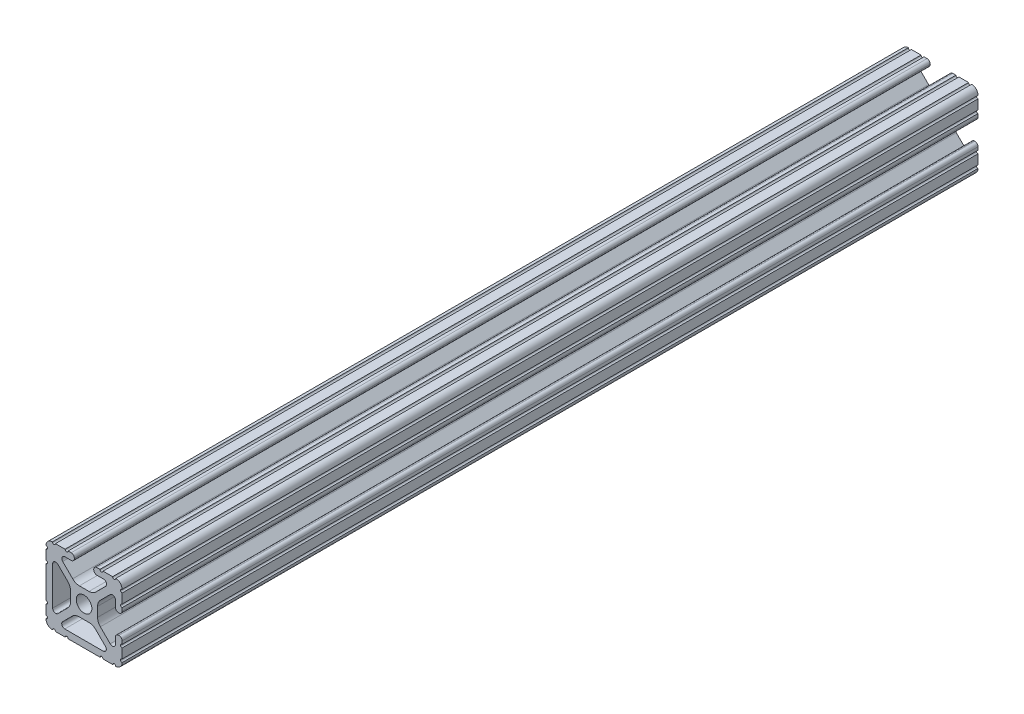
from build123d import *

# Parameters (mm, degrees)
SKETCH3_R                = 2.6035
BOSS_EXTRUDE1_DEPTH      = 142.875
BOSS_EXTRUDE1_DEPTH_BACK = 142.875


with BuildPart() as part:
    # Sketch3 → Boss-Extrude1 (new body, two sides)
    with BuildSketch(Plane.XY) as boss_extrude1_sk:
        with BuildLine():
            Line((6.3331344, -12.7), (9.5504, -12.7))
            ThreePointArc((9.5504, -12.7), (10.058323491, -12.192000006), (10.566399977, -12.699846982))
            ThreePointArc((10.566399977, -12.699846982), (12.082522516, -12.082522516), (12.699846982, -10.566399977))
            ThreePointArc((12.699846982, -10.566399977), (12.192000006, -10.058323491), (12.7, -9.5504))
            Line((12.7, -9.5504), (12.7, -6.3330836))
            ThreePointArc((12.7, -6.3330836), (12.192, -5.8250836), (12.7, -5.3170836))
            Line((12.7, -5.3170836), (12.7, -4.28752))
            ThreePointArc((12.7, -4.28752), (12.392749156, -3.545750844), (11.65098, -3.2385))
            Line((11.65098, -3.2385), (11.53922, -3.2385))
            ThreePointArc((11.53922, -3.2385), (10.797450844, -3.545750844), (10.4902, -4.28752))
            Line((10.4902, -4.28752), (10.4902, -6.402089023))
            ThreePointArc((10.4902, -6.402089023), (9.856394933, -7.351113629), (8.736962546, -7.129240479))
            Line((8.736962546, -7.129240479), (5.440484187, -3.838768792))
            ThreePointArc((5.440484187, -3.838768792), (4.75073678, -2.808015636), (4.5085, -1.591658411))
            Line((4.5085, -1.591658411), (4.5085, 1.591658411))
            ThreePointArc((4.5085, 1.591658411), (4.75073678, 2.808015636), (5.440484187, 3.838768792))
            Line((5.440484187, 3.838768792), (8.736962546, 7.129240479))
            ThreePointArc((8.736962546, 7.129240479), (9.856394933, 7.351113629), (10.4902, 6.402089023))
            Line((10.4902, 6.402089023), (10.4902, 4.28752))
            ThreePointArc((10.4902, 4.28752), (10.797450844, 3.545750844), (11.53922, 3.2385))
            Line((11.53922, 3.2385), (11.65098, 3.2385))
            ThreePointArc((11.65098, 3.2385), (12.392749156, 3.545750844), (12.7, 4.28752))
            Line((12.7, 4.28752), (12.7, 5.3171344))
            ThreePointArc((12.7, 5.3171344), (12.192, 5.8251344), (12.7, 6.3331344))
            Line((12.7, 6.3331344), (12.7, 9.5504))
            ThreePointArc((12.7, 9.5504), (12.192000006, 10.058323491), (12.699846982, 10.566399977))
            ThreePointArc((12.699846982, 10.566399977), (12.082522516, 12.082522516), (10.566399977, 12.699846982))
            ThreePointArc((10.566399977, 12.699846982), (10.058323491, 12.192000006), (9.5504, 12.7))
            Line((9.5504, 12.7), (6.3330836, 12.7))
            ThreePointArc((6.3330836, 12.7), (5.8250836, 12.192), (5.3170836, 12.7))
            Line((5.3170836, 12.7), (4.28752, 12.7))
            ThreePointArc((4.28752, 12.7), (3.545750844, 12.392749156), (3.2385, 11.65098))
            Line((3.2385, 11.65098), (3.2385, 11.53922))
            ThreePointArc((3.2385, 11.53922), (3.545750844, 10.797450844), (4.28752, 10.4902))
            Line((4.28752, 10.4902), (6.476795923, 10.4902))
            ThreePointArc((6.476795923, 10.4902), (7.432175542, 9.851520654), (7.207206853, 8.724555432))
            Line((7.207206853, 8.724555432), (3.900315394, 5.423689619))
            ThreePointArc((3.900315394, 5.423689619), (2.8709819, 4.736928798), (1.657299581, 4.4958))
            Line((1.657299581, 4.4958), (-1.553667902, 4.4958))
            ThreePointArc((-1.553667902, 4.4958), (-2.767350221, 4.736928798), (-3.796683715, 5.423689619))
            Line((-3.796683715, 5.423689619), (-7.134200223, 8.755124678))
            ThreePointArc((-7.134200223, 8.755124678), (-7.355273948, 9.862578342), (-6.416435163, 10.4902))
            Line((-6.416435163, 10.4902), (-4.28752, 10.4902))
            ThreePointArc((-4.28752, 10.4902), (-3.545750844, 10.797450844), (-3.2385, 11.53922))
            Line((-3.2385, 11.53922), (-3.2385, 11.65098))
            ThreePointArc((-3.2385, 11.65098), (-3.545750844, 12.392749156), (-4.28752, 12.7))
            Line((-4.28752, 12.7), (-5.3171344, 12.7))
            ThreePointArc((-5.3171344, 12.7), (-5.8251344, 12.192), (-6.3331344, 12.7))
            Line((-6.3331344, 12.7), (-9.5504, 12.7))
            ThreePointArc((-9.5504, 12.7), (-10.058323491, 12.192000006), (-10.566399977, 12.699846982))
            ThreePointArc((-10.566399977, 12.699846982), (-12.082522516, 12.082522516), (-12.699846982, 10.566399977))
            ThreePointArc((-12.699846982, 10.566399977), (-12.192000006, 10.058323491), (-12.7, 9.5504))
            Line((-12.7, 9.5504), (-12.7, 6.3331344))
            ThreePointArc((-12.7, 6.3331344), (-12.192, 5.8251344), (-12.7, 5.3171344))
            Line((-12.7, 5.3171344), (-12.7, -5.3170836))
            ThreePointArc((-12.7, -5.3170836), (-12.192, -5.8250836), (-12.7, -6.3330836))
            Line((-12.7, -6.3330836), (-12.7, -9.5504))
            ThreePointArc((-12.7, -9.5504), (-12.192000006, -10.058323491), (-12.699846982, -10.566399977))
            ThreePointArc((-12.699846982, -10.566399977), (-12.082522516, -12.082522516), (-10.566399977, -12.699846982))
            ThreePointArc((-10.566399977, -12.699846982), (-10.058323491, -12.192000006), (-9.5504, -12.7))
            Line((-9.5504, -12.7), (-6.3330836, -12.7))
            ThreePointArc((-6.3330836, -12.7), (-5.8250836, -12.192), (-5.3170836, -12.7))
            Line((-5.3170836, -12.7), (5.3171344, -12.7))
            ThreePointArc((5.3171344, -12.7), (5.8251344, -12.192), (6.3331344, -12.7))
        make_face()
        Circle(SKETCH3_R, mode=Mode.SUBTRACT)
        with BuildLine():
            Line((-8.753441447, -7.145689354), (-5.440484187, -3.838768792))
            ThreePointArc((-5.440484187, -3.838768792), (-4.75073678, -2.808015636), (-4.5085, -1.591658411))
            Line((-4.5085, -1.591658411), (-4.5085, 1.591658411))
            ThreePointArc((-4.5085, 1.591658411), (-4.75073678, 2.808015636), (-5.440484187, 3.838768792))
            Line((-5.440484187, 3.838768792), (-8.736962546, 7.129240479))
            ThreePointArc((-8.736962546, 7.129240479), (-9.856394933, 7.351113629), (-10.4902, 6.402089023))
            Line((-10.4902, 6.402089023), (-10.4902, -6.425372487))
            ThreePointArc((-10.4902, -6.425372487), (-9.862352148, -7.36547709), (-8.753441447, -7.145689354))
        make_face(mode=Mode.SUBTRACT)
        with BuildLine():
            Line((7.147805753, -8.66526257), (3.900315394, -5.423689619))
            ThreePointArc((3.900315394, -5.423689619), (2.8709819, -4.736928798), (1.657299581, -4.4958))
            Line((1.657299581, -4.4958), (-1.657299581, -4.4958))
            ThreePointArc((-1.657299581, -4.4958), (-2.8709819, -4.736928798), (-3.900315394, -5.423689619))
            Line((-3.900315394, -5.423689619), (-7.153722341, -8.671168377))
            ThreePointArc((-7.153722341, -8.671168377), (-7.374796065, -9.77862204), (-6.435957281, -10.406243698))
            Line((-6.435957281, -10.406243698), (6.427597582, -10.406243698))
            ThreePointArc((6.427597582, -10.406243698), (7.369631963, -9.776485757), (7.147805753, -8.66526257))
        make_face(mode=Mode.SUBTRACT)
    extrude(amount=BOSS_EXTRUDE1_DEPTH)
    extrude(boss_extrude1_sk.sketch, amount=-BOSS_EXTRUDE1_DEPTH_BACK)


solid = part.part
